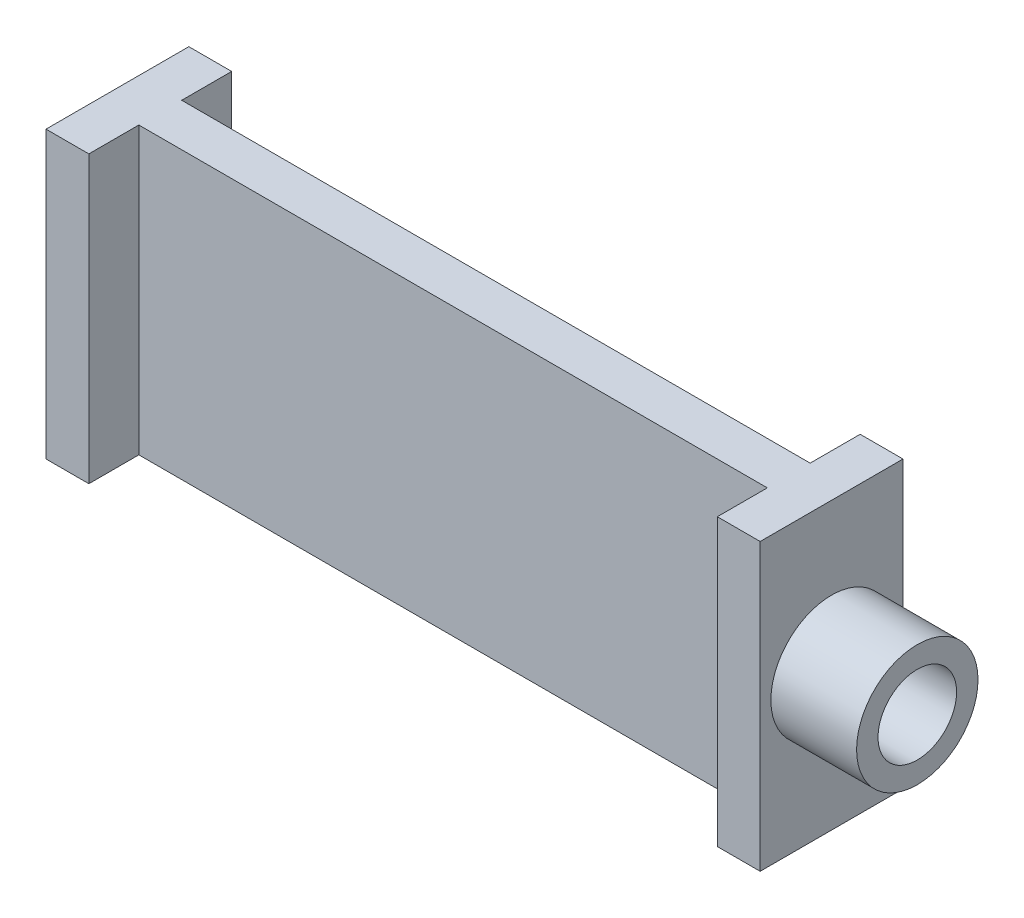
from build123d import *

# Parameters (mm, degrees)
BOSS_EXTRUDE2_DEPTH = 40
SKETCH2_R           = 8.5
SKETCH2_R_2         = 5.5
BOSS_EXTRUDE3_DEPTH = 12


with BuildPart() as part:
    # Sketch1 → Boss-Extrude2 (new body)
    with BuildSketch(Plane(origin=(0, 0, 0), x_dir=(1, 0, 0), z_dir=(0, 1, 0))):
        Polygon((0, 0), (0, 20), (6, 20), (6, 13), (94, 13), (94, 20), (100, 20), (100, 0), (94, 0), (94, 7), (6, 7), (6, 0), align=None)
    extrude(amount=BOSS_EXTRUDE2_DEPTH)

    # Sketch2 → Boss-Extrude3 (add)
    with BuildSketch(Plane(origin=(100, 0, 0), x_dir=(0, 0, -1), z_dir=(1, 0, 0))):
        with Locations((10, 20)):
            Circle(SKETCH2_R)
        with Locations((10, 20)):
            Circle(SKETCH2_R_2, mode=Mode.SUBTRACT)
    extrude(amount=BOSS_EXTRUDE3_DEPTH)


solid = part.part
